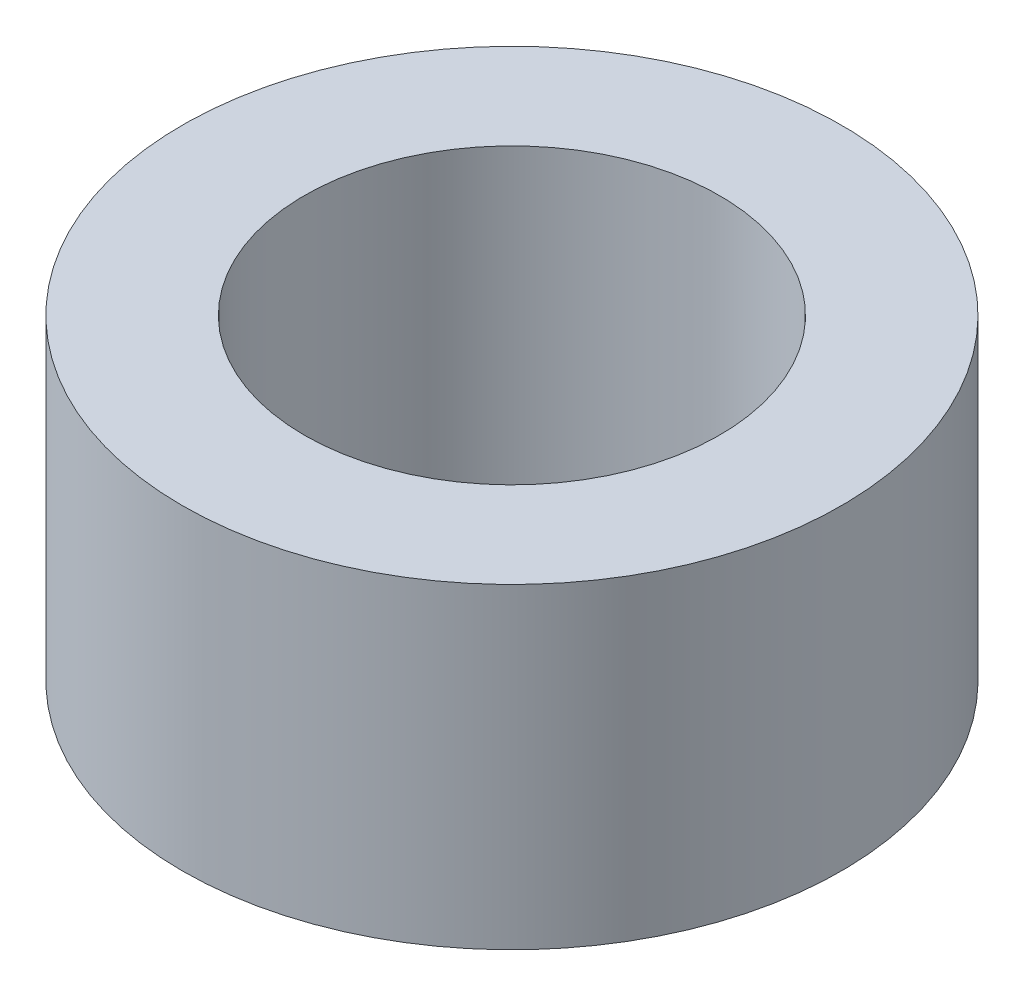
from build123d import *

# Parameters (mm, degrees)
SKETCH1_R           = 3.175
SKETCH1_R_2         = 1.999996
BOSS_EXTRUDE1_DEPTH = 3.048


with BuildPart() as part:
    # Sketch1 → Boss-Extrude1 (new body)
    with BuildSketch(Plane(origin=(0, 0, 0), x_dir=(1, 0, 0), z_dir=(0, 1, 0))):
        Circle(SKETCH1_R)
        Circle(SKETCH1_R_2, mode=Mode.SUBTRACT)
    extrude(amount=-BOSS_EXTRUDE1_DEPTH)


solid = part.part
